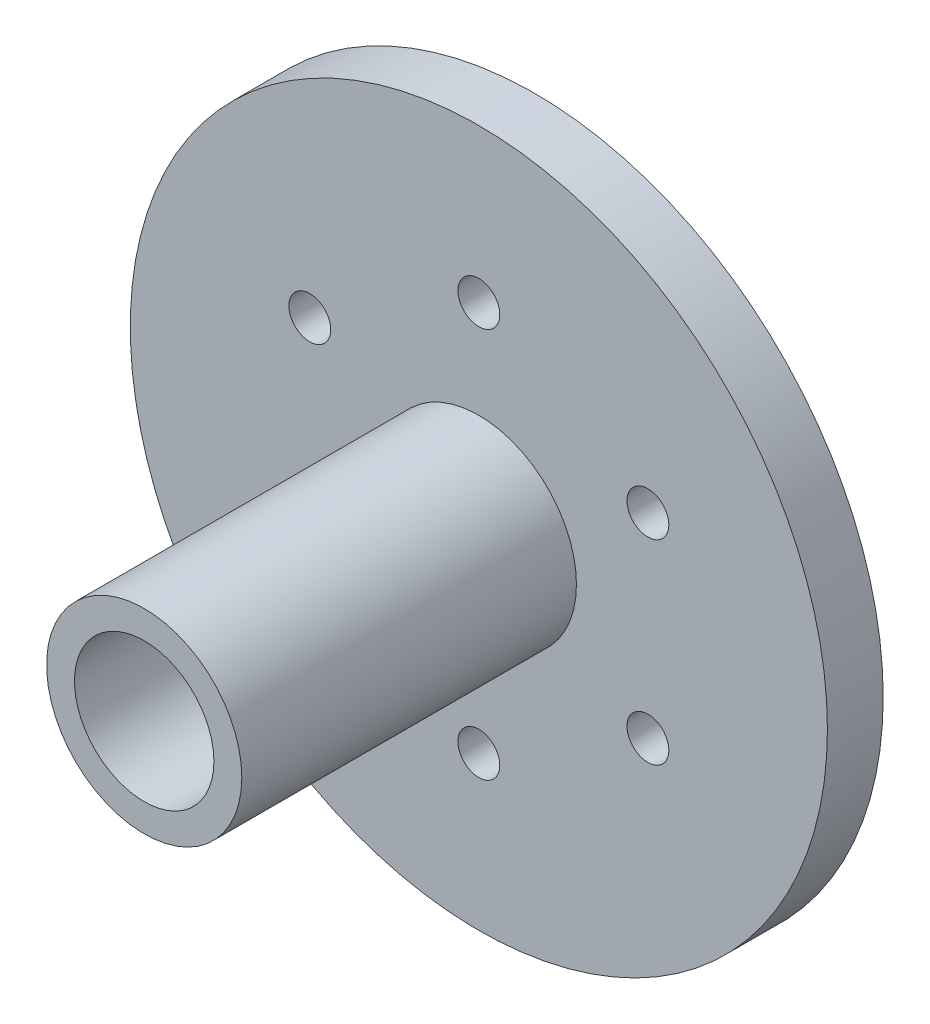
from build123d import *

# Parameters (mm, degrees)
SKETCH1_R           = 25
BOSS_EXTRUDE1_DEPTH = 4
SKETCH2_R           = 7
SKETCH2_R_2         = 5
BOSS_EXTRUDE2_DEPTH = 24
SKETCH3_R           = 1.5
CUT_EXTRUDE1_DEPTH  = 24


with BuildPart() as part:
    # Sketch1 → Boss-Extrude1 (new body)
    with BuildSketch(Plane.XY):
        Circle(SKETCH1_R)
    extrude(amount=BOSS_EXTRUDE1_DEPTH)

    # Sketch2 → Boss-Extrude2 (add)
    with BuildSketch(Plane.XY.offset(4)):
        Circle(SKETCH2_R)
        Circle(SKETCH2_R_2, mode=Mode.SUBTRACT)
    extrude(amount=BOSS_EXTRUDE2_DEPTH)

    # Sketch3 → Cut-Extrude1 (cut)
    with BuildSketch(Plane(origin=(0, 0, 0), x_dir=(-1, 0, 0), z_dir=(0, 0, -1))):
        with Locations((0, 14)):
            Circle(SKETCH3_R)
        with Locations((12.124355653, 7)):
            Circle(SKETCH3_R)
        with Locations((12.124355653, -7)):
            Circle(SKETCH3_R)
        with Locations((0, -14)):
            Circle(SKETCH3_R)
        with Locations((-12.124355653, -7)):
            Circle(SKETCH3_R)
        with Locations((-12.124355653, 7)):
            Circle(SKETCH3_R)
    extrude(amount=-CUT_EXTRUDE1_DEPTH, mode=Mode.SUBTRACT)


solid = part.part
